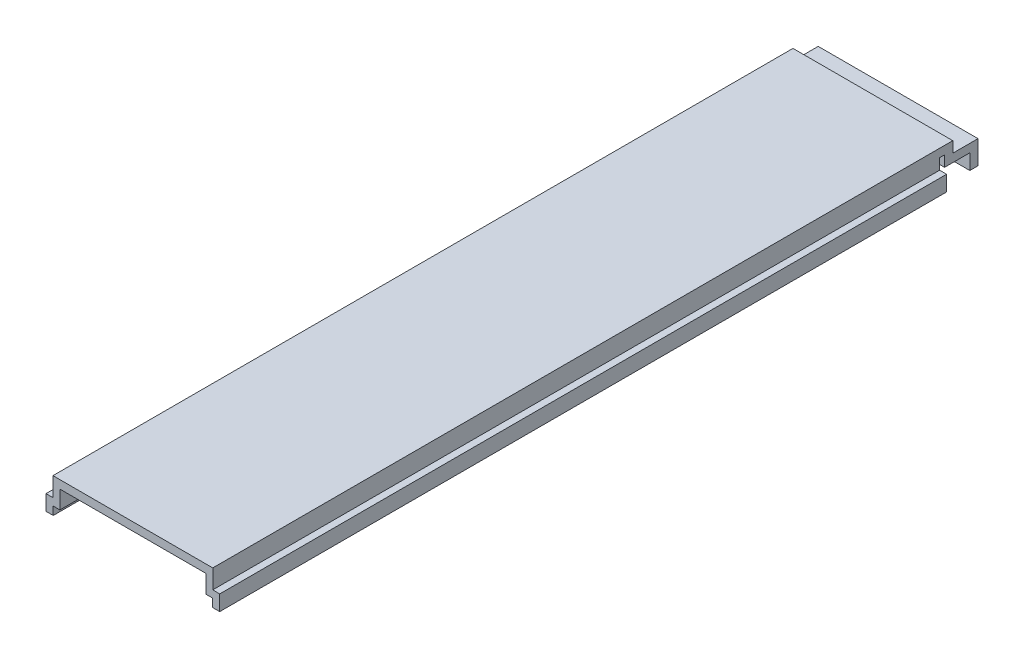
from build123d import *

# Parameters (mm, degrees)
BOSS_EXTRUDE1_DEPTH = 282
BOSS_EXTRUDE2_DEPTH = 62


with BuildPart() as part:
    # Sketch1 → Boss-Extrude1 (new body)
    with BuildSketch(Plane.XY):
        Polygon((-2.36, 23.687204572), (59.64, 23.687204572), (59.64, 16.298774949), (62.34, 16.298774949), (62.34, 10.337204572), (59.54, 10.337204572), (59.54, 13.512204572), (56.94, 13.512204572), (56.94, 20.512204572), (0.34, 20.512204572), (0.34, 13.512204572), (-2.26, 13.512204572), (-2.26, 10.337204572), (-5.06, 10.337204572), (-5.06, 16.298774949), (-2.36, 16.298774949), align=None)
    extrude(amount=BOSS_EXTRUDE1_DEPTH)

    # Sketch5 → Boss-Extrude2 (add)
    with BuildSketch(Plane.ZY.offset(2.36)):
        Polygon((0, 23.687204572), (-5.1, 23.687204572), (-5.1, 19.473774949), (-14.890029998, 19.473774949), (-14.890029998, 10.337204572), (-11.715029998, 10.337204572), (-11.715029998, 16.298774949), (-1.925, 16.298774949), (-1.925, 20.512204572), (0, 20.512204572), align=None)
    extrude(amount=-BOSS_EXTRUDE2_DEPTH)


solid = part.part
